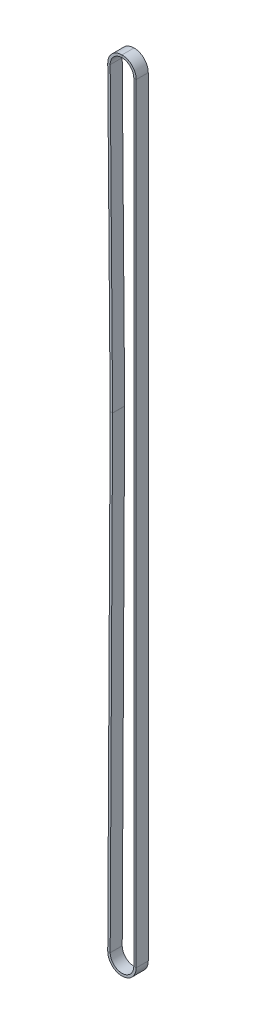
from build123d import *

# Parameters (mm, degrees)
SKETCH3_W = 7.366
SKETCH3_H = 1.5


with BuildPart() as part:
    # Sweep1: sweep along a path in Sketch2
    with BuildLine(Plane.XY) as sweep1_path:
        Line((-7.217959412, 0.037533359), (-5.727035895, 286.753819557))
        ThreePointArc((-5.727035895, 286.753819557), (-5.72700281, 286.771488203), (-5.727087308, 286.789156677))
        Line((-5.727087308, 286.789156677), (-7.217819637, 470.60346355))
        ThreePointArc((-7.217819637, 470.60346355), (-0.029268466, 477.879997648), (7.218056998, 470.662))
        Line((7.218056998, 470.662), (7.218056998, 0))
        ThreePointArc((7.218056998, 0), (-0.018766743, -7.218032601), (-7.217959412, 0.037533359))
    # Sketch3 → Sweep1 (sweep)
    with BuildSketch(Plane(origin=(0, 0, 0), x_dir=(0, 0, -1), z_dir=(1, 0, 0))):
        with Locations((3.683, 478.630056998)):
            Rectangle(SKETCH3_W, SKETCH3_H)
    sweep(path=sweep1_path.line)


solid = part.part
